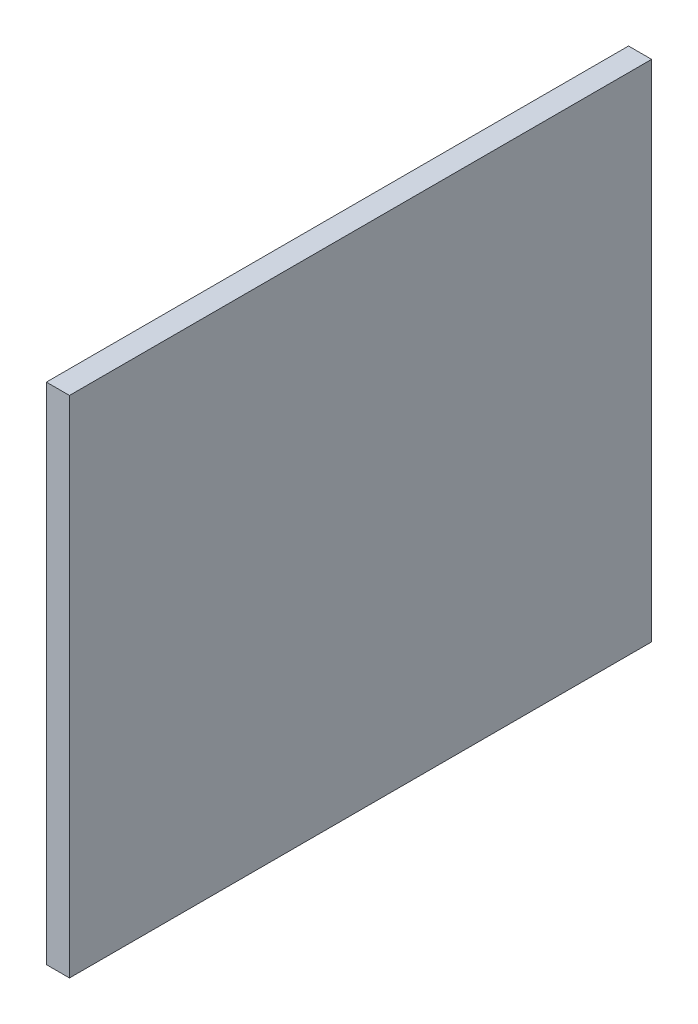
from build123d import *

# Parameters (mm, degrees)
SKETCH1_W           = 120
SKETCH1_H           = 104
BOSS_EXTRUDE1_DEPTH = 4.7625


with BuildPart() as part:
    # Sketch1 → Boss-Extrude1 (new body)
    with BuildSketch(Plane(origin=(0, 0, 0), x_dir=(0, 0, -1), z_dir=(1, 0, 0))):
        Rectangle(SKETCH1_W, SKETCH1_H)
    extrude(amount=BOSS_EXTRUDE1_DEPTH)


solid = part.part
